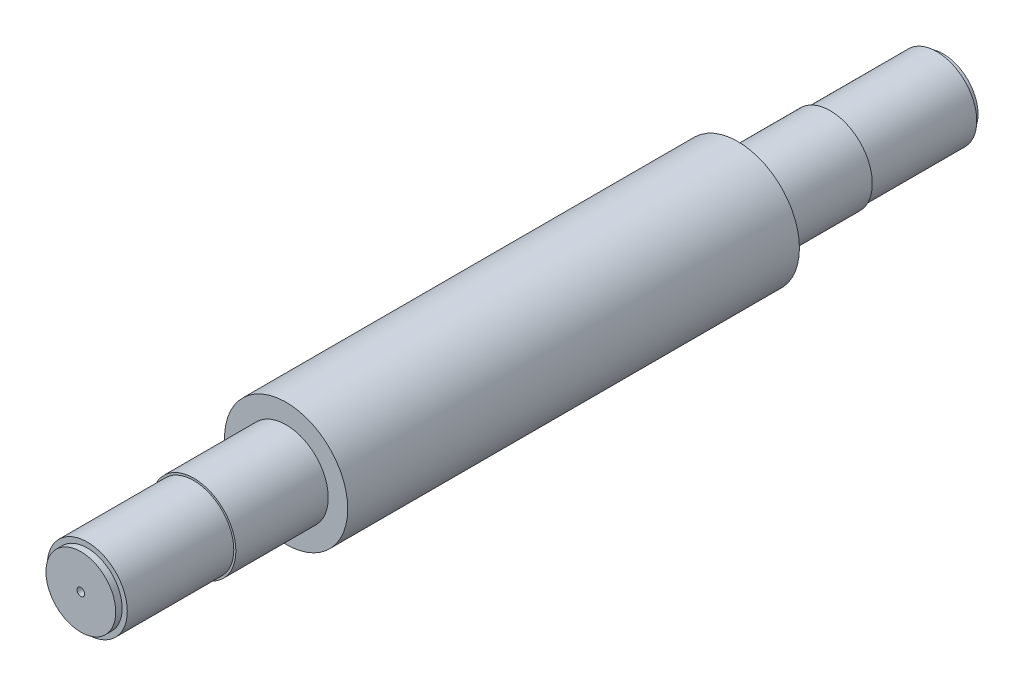
from build123d import *

# Parameters (mm, degrees)
SKETCH1_R           = 60
BOSS_EXTRUDE1_DEPTH = 440
SKETCH2_R           = 41
BOSS_EXTRUDE2_DEPTH = 90
SKETCH3_R           = 41
BOSS_EXTRUDE3_DEPTH = 90
SKETCH4_R           = 39
BOSS_EXTRUDE4_DEPTH = 103.75
SKETCH5_R           = 39
BOSS_EXTRUDE5_DEPTH = 103.75
SKETCH6_R           = 34
BOSS_EXTRUDE6_DEPTH = 6.25
SKETCH7_R           = 34
BOSS_EXTRUDE7_DEPTH = 6.25
SKETCH8_R           = 3.75
CUT_EXTRUDE1_DEPTH  = 840


with BuildPart() as part:
    # Sketch1 → Boss-Extrude1 (new body)
    with BuildSketch(Plane.XY):
        Circle(SKETCH1_R)
    extrude(amount=BOSS_EXTRUDE1_DEPTH)

    # Sketch2 → Boss-Extrude2 (add)
    with BuildSketch(Plane(origin=(0, 0, 0), x_dir=(-1, 0, 0), z_dir=(0, 0, -1))):
        Circle(SKETCH2_R)
    extrude(amount=BOSS_EXTRUDE2_DEPTH)

    # Sketch3 → Boss-Extrude3 (add)
    with BuildSketch(Plane.XY.offset(440)):
        Circle(SKETCH3_R)
    extrude(amount=BOSS_EXTRUDE3_DEPTH)

    # Sketch4 → Boss-Extrude4 (add)
    with BuildSketch(Plane.XY.offset(530)):
        Circle(SKETCH4_R)
    extrude(amount=BOSS_EXTRUDE4_DEPTH)

    # Sketch5 → Boss-Extrude5 (add)
    with BuildSketch(Plane(origin=(0, 0, -90), x_dir=(-1, 0, 0), z_dir=(0, 0, -1))):
        Circle(SKETCH5_R)
    extrude(amount=BOSS_EXTRUDE5_DEPTH)

    # Sketch6 → Boss-Extrude6 (add)
    with BuildSketch(Plane(origin=(0, 0, -193.75), x_dir=(-1, 0, 0), z_dir=(0, 0, -1))):
        Circle(SKETCH6_R)
    extrude(amount=BOSS_EXTRUDE6_DEPTH)

    # Sketch7 → Boss-Extrude7 (add)
    with BuildSketch(Plane.XY.offset(633.75)):
        Circle(SKETCH7_R)
    extrude(amount=BOSS_EXTRUDE7_DEPTH)

    # Sketch8 → Cut-Extrude1 (cut)
    with BuildSketch(Plane.XY.offset(640)):
        Circle(SKETCH8_R)
    extrude(amount=-CUT_EXTRUDE1_DEPTH, mode=Mode.SUBTRACT)


solid = part.part
